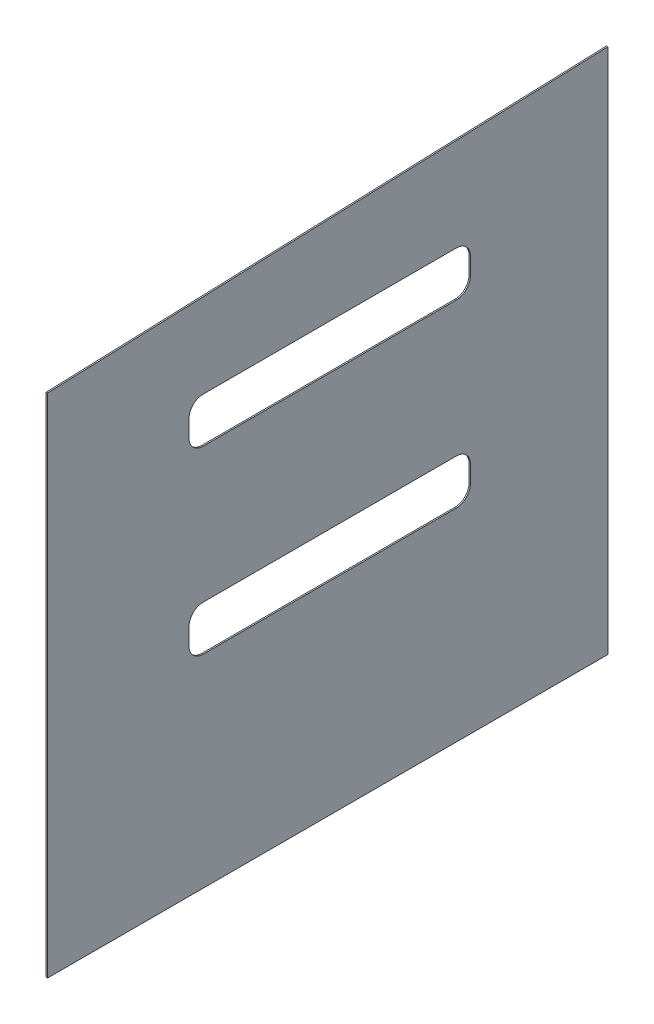
from build123d import *

# Parameters (mm, degrees)
BOSS_EXTRUDE1_DEPTH = 6.35
CUT_EXTRUDE1_DEPTH  = 50.8


with BuildPart() as part:
    # Sketch1 → Boss-Extrude1 (new body)
    with BuildSketch(Plane(origin=(0, 0, 0), x_dir=(0, 0, -1), z_dir=(1, 0, 0))):
        Polygon((-746.398166827, -447.542708333), (1780.901833173, -447.542708333), (1780.901833173, 1927.357291667), (-746.398166827, 1838.457291667), align=None)
    extrude(amount=BOSS_EXTRUDE1_DEPTH)

    # Sketch2 → Cut-Extrude1 (cut)
    with BuildSketch(Plane(origin=(6.35, 0, 0), x_dir=(0, 0, -1), z_dir=(1, 0, 0))):
        with BuildLine():
            Line((-45.100318004, 670.057291667), (1097.899681996, 670.057291667))
            ThreePointArc((1097.899681996, 670.057291667), (1142.800962601, 651.458572272), (1161.399681996, 606.557291667))
            Line((1161.399681996, 606.557291667), (1161.399681996, 530.357291667))
            ThreePointArc((1161.399681996, 530.357291667), (1142.800962601, 485.456011061), (1097.899681996, 466.857291667))
            Line((1097.899681996, 466.857291667), (-45.100318004, 466.857291667))
            ThreePointArc((-45.100318004, 466.857291667), (-90.001598609, 485.456011061), (-108.600318004, 530.357291667))
            Line((-108.600318004, 530.357291667), (-108.600318004, 606.557291667))
            ThreePointArc((-108.600318004, 606.557291667), (-90.001598609, 651.458572272), (-45.100318004, 670.057291667))
        make_face()
        with BuildLine():
            Line((1097.899681996, 1482.857291667), (-45.100318004, 1482.857291667))
            ThreePointArc((-45.100318004, 1482.857291667), (-90.001598609, 1464.258572272), (-108.600318004, 1419.357291667))
            Line((-108.600318004, 1419.357291667), (-108.600318004, 1343.157291667))
            ThreePointArc((-108.600318004, 1343.157291667), (-90.001598609, 1298.256011061), (-45.100318004, 1279.657291667))
            Line((-45.100318004, 1279.657291667), (1097.899681996, 1279.657291667))
            ThreePointArc((1097.899681996, 1279.657291667), (1142.800962601, 1298.256011061), (1161.399681996, 1343.157291667))
            Line((1161.399681996, 1343.157291667), (1161.399681996, 1419.357291667))
            ThreePointArc((1161.399681996, 1419.357291667), (1142.800962601, 1464.258572272), (1097.899681996, 1482.857291667))
        make_face()
    extrude(amount=-CUT_EXTRUDE1_DEPTH, mode=Mode.SUBTRACT)


solid = part.part
